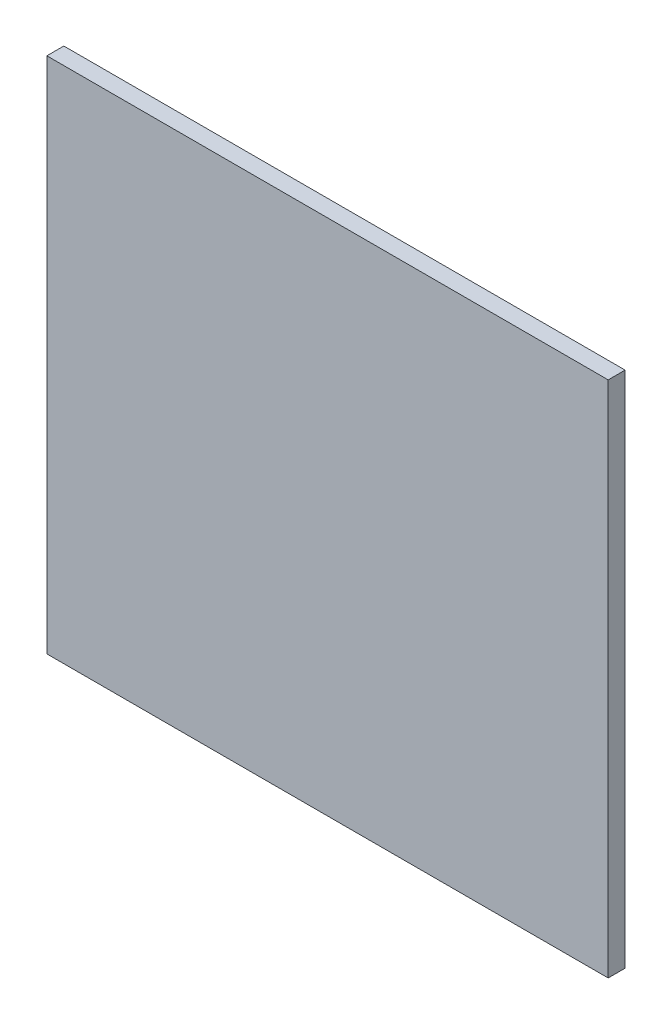
from build123d import *

# Parameters (mm, degrees)
SKETCH1_W           = 596
SKETCH1_H           = 550
BOSS_EXTRUDE1_DEPTH = 18


with BuildPart() as part:
    # Sketch1 → Boss-Extrude1 (new body)
    with BuildSketch(Plane.XY):
        with Locations((250.248815741, 238.498528931)):
            Rectangle(SKETCH1_W, SKETCH1_H)
    extrude(amount=BOSS_EXTRUDE1_DEPTH)


solid = part.part
